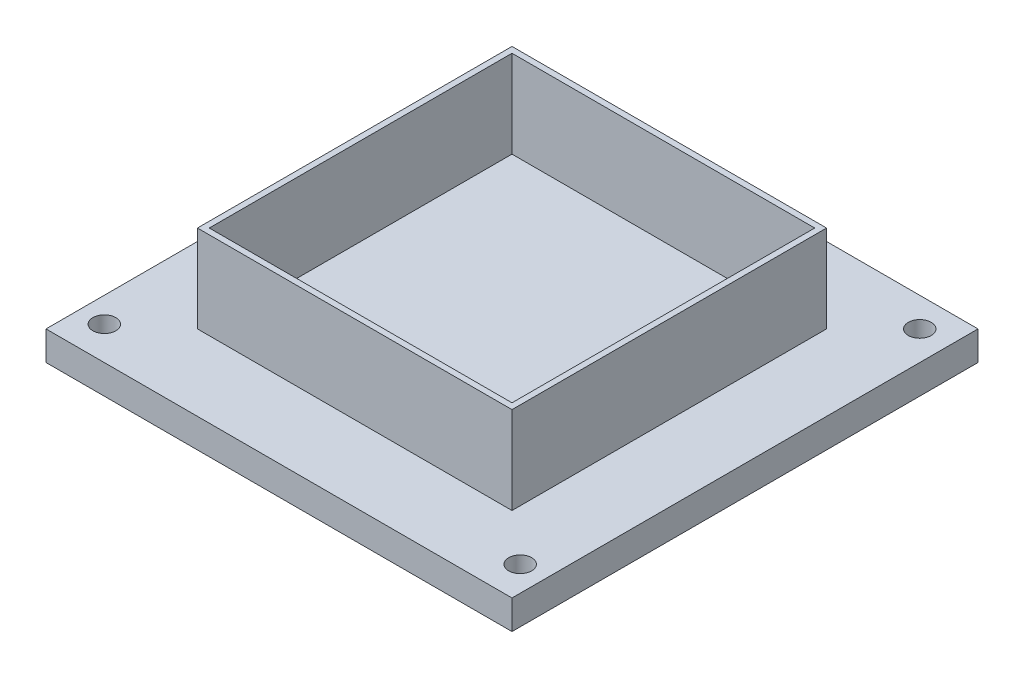
from build123d import *

# Parameters (mm, degrees)
SKETCH1_W           = 68.58
SKETCH1_H           = 68.58
SKETCH1_W_2         = 66
SKETCH1_H_2         = 66
BOSS_EXTRUDE1_DEPTH = 25.4
SKETCH2_W           = 101.6
SKETCH2_H           = 101.6
BOSS_EXTRUDE2_DEPTH = 6.35
SKETCH3_R           = 2.5
CUT_EXTRUDE1_DEPTH  = 7.35


with BuildPart() as part:
    # Sketch1 → Boss-Extrude1 (new body)
    with BuildSketch(Plane(origin=(0, 0, 0), x_dir=(1, 0, 0), z_dir=(0, 1, 0))):
        Rectangle(SKETCH1_W, SKETCH1_H)
        Rectangle(SKETCH1_W_2, SKETCH1_H_2, mode=Mode.SUBTRACT)
    extrude(amount=BOSS_EXTRUDE1_DEPTH)

    # Sketch2 → Boss-Extrude2 (add)
    with BuildSketch(Plane(origin=(0, 0, 0), x_dir=(1, 0, 0), z_dir=(0, 1, 0))):
        Rectangle(SKETCH2_W, SKETCH2_H)
    extrude(amount=BOSS_EXTRUDE2_DEPTH)

    # Sketch3 → Cut-Extrude1 (cut, through all)
    with BuildSketch(Plane(origin=(0, 6.35, 0), x_dir=(1, 0, 0), z_dir=(0, 1, 0))):
        with Locations((-44.45, 44.45)):
            Circle(SKETCH3_R)
        with Locations((-45.331774214, -43.550375964)):
            Circle(SKETCH3_R)
        with Locations((45.331774214, -43.550375964)):
            Circle(SKETCH3_R)
        with Locations((44.45, 44.45)):
            Circle(SKETCH3_R)
    extrude(amount=-CUT_EXTRUDE1_DEPTH, mode=Mode.SUBTRACT)


solid = part.part
